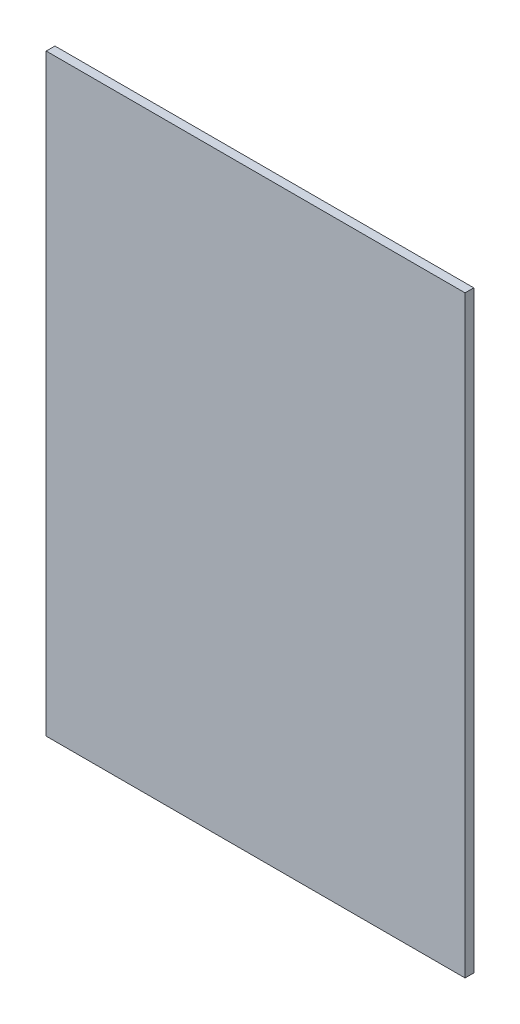
from build123d import *

# Parameters (mm, degrees)
ESQUISSE1_W        = 480
ESQUISSE1_H        = 680
BOSS_EXTRU_1_DEPTH = 10


with BuildPart() as part:
    # Esquisse1 → Boss.-Extru.1 (new body)
    with BuildSketch(Plane.XY):
        with Locations((-50, 0)):
            Rectangle(ESQUISSE1_W, ESQUISSE1_H)
    extrude(amount=BOSS_EXTRU_1_DEPTH)


solid = part.part
